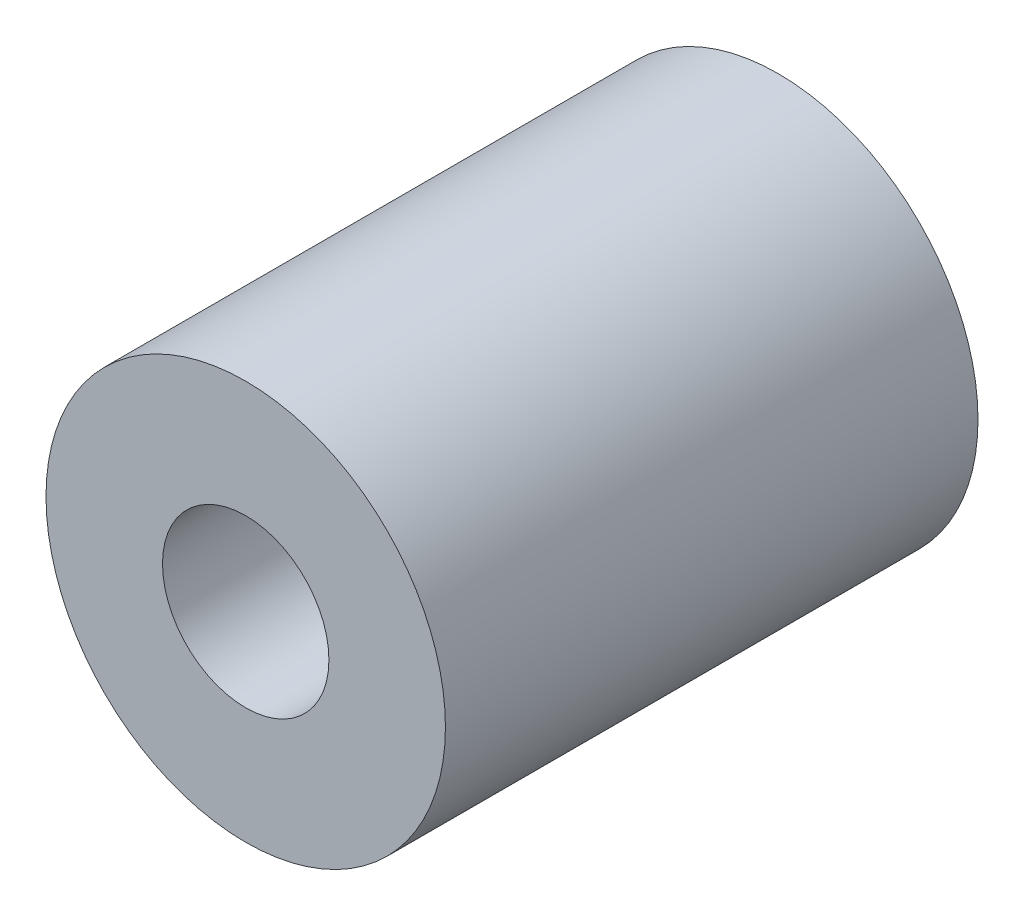
from build123d import *

# Parameters (mm, degrees)
SKETCH1_R           = 19.05
BOSS_EXTRUDE1_DEPTH = 50.8
SKETCH2_R           = 7.9375
CUT_EXTRUDE1_DEPTH  = 63.5


with BuildPart() as part:
    # Sketch1 → Boss-Extrude1 (new body)
    with BuildSketch(Plane.XY):
        Circle(SKETCH1_R)
    extrude(amount=-BOSS_EXTRUDE1_DEPTH)

    # Sketch2 → Cut-Extrude1 (cut)
    with BuildSketch(Plane.XY):
        Circle(SKETCH2_R)
    extrude(amount=-CUT_EXTRUDE1_DEPTH, mode=Mode.SUBTRACT)


solid = part.part
